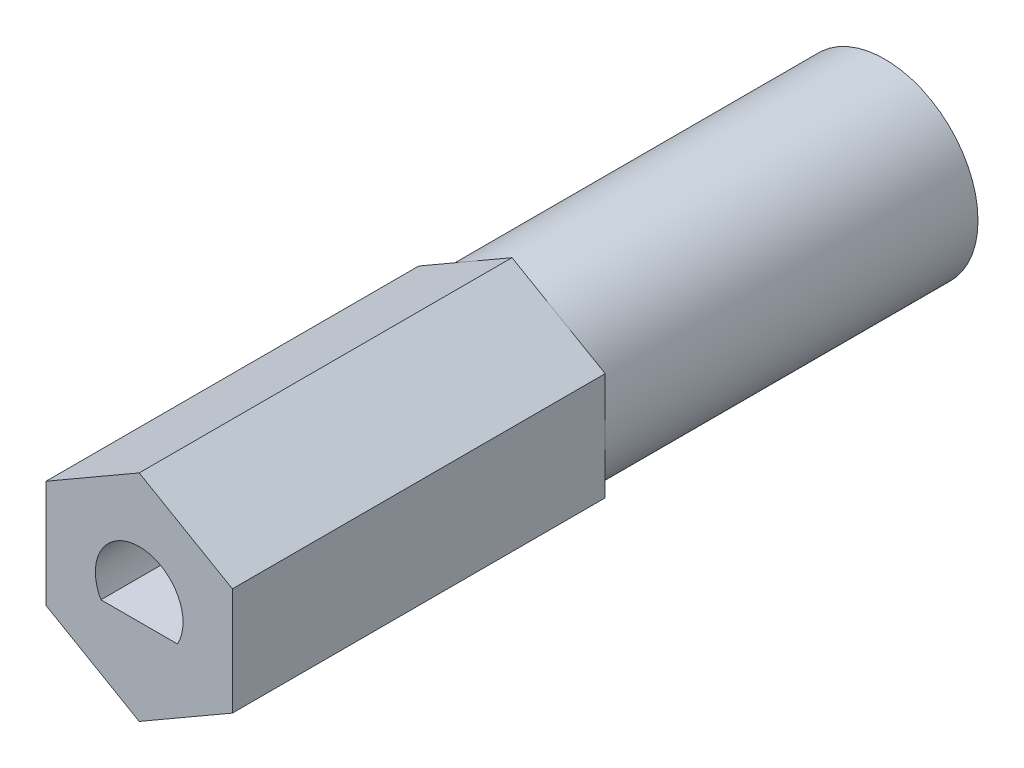
from build123d import *

# Parameters (mm, degrees)
BOSS_EXTRUDE1_DEPTH = 25.4
CUT_EXTRUDE1_DEPTH  = 5.08
SKETCH3_OUTSIDE_W   = 13.788
SKETCH3_OUTSIDE_H   = 14.77
SKETCH3_OUTSIDE_R   = 3.175
CUT_EXTRUDE2_DEPTH  = 13.7


with BuildPart() as part:
    # Sketch1 → Boss-Extrude1 (new body)
    with BuildSketch(Plane.XY):
        Polygon((0, 3.666174209), (-3.175, 1.833087105), (-3.175, -1.833087105), (0, -3.666174209), (3.175, -1.833087105), (3.175, 1.833087105), align=None)
    extrude(amount=-BOSS_EXTRUDE1_DEPTH)

    # Sketch2 → Cut-Extrude1 (cut)
    with BuildSketch(Plane.XY):
        with BuildLine():
            Line((-1.303529881, -0.72898), (1.303529881, -0.72898))
            ThreePointArc((1.303529881, -0.72898), (0, 1.49352), (-1.303529881, -0.72898))
        make_face()
    extrude(amount=-CUT_EXTRUDE1_DEPTH, mode=Mode.SUBTRACT)

    # Sketch3 outside → Cut-Extrude2 (cut, through all)
    with BuildSketch(Plane.XY.offset(-12.7)):
        Rectangle(SKETCH3_OUTSIDE_W, SKETCH3_OUTSIDE_H)
        Circle(SKETCH3_OUTSIDE_R, mode=Mode.SUBTRACT)
    extrude(amount=-CUT_EXTRUDE2_DEPTH, mode=Mode.SUBTRACT)


solid = part.part
